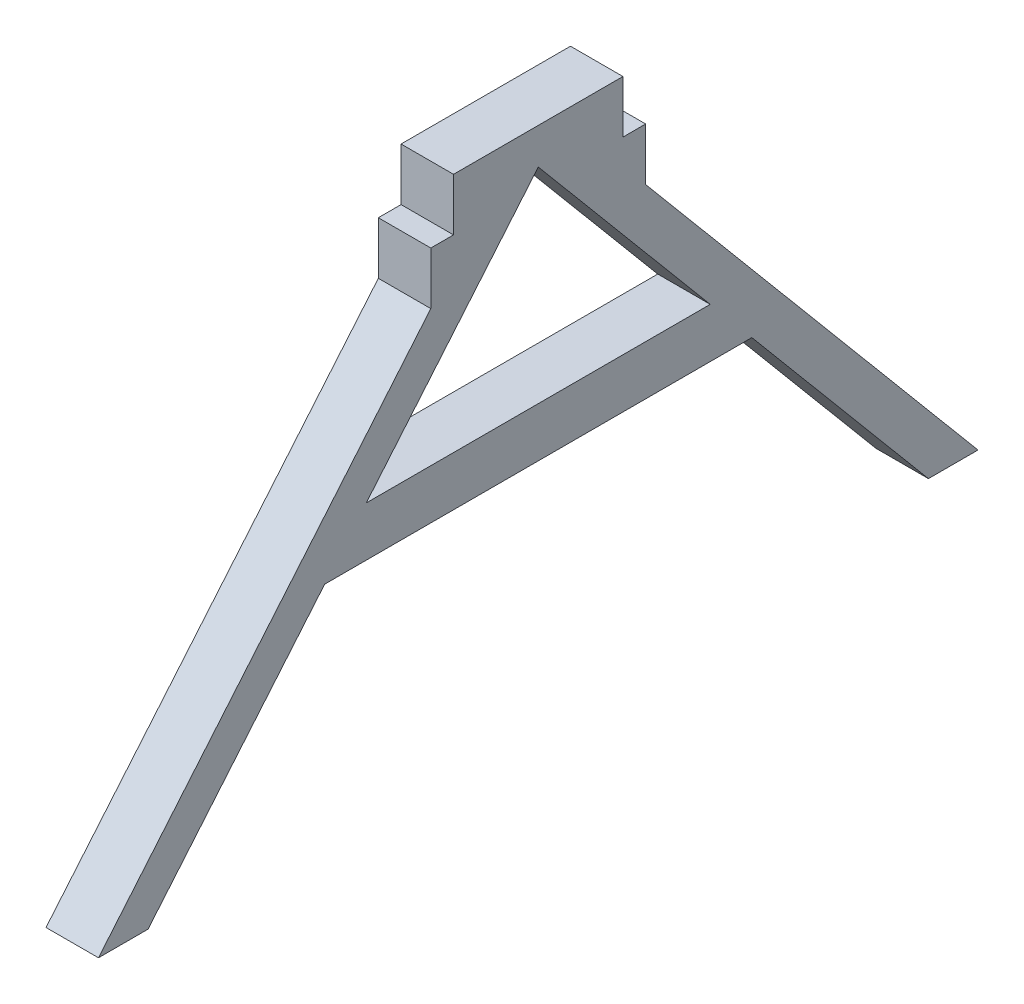
from build123d import *

# Parameters (mm, degrees)
BOSS_EXTRUDE2_DEPTH = 3.175


with BuildPart() as part:
    # Sketch1 → Boss-Extrude2 (new body)
    with BuildSketch(Plane(origin=(0, 0, 0), x_dir=(0, 0, -1), z_dir=(1, 0, 0))):
        Polygon((0.727545577, -5.496236961), (-19.379740188, -29.459167008), (-16.379740188, -29.459167008), (-5.695435338, -16.726108319), (20.150526491, -16.726108319), (30.834831341, -29.459167008), (33.834831341, -29.459167008), (13.727545577, -5.496236961), (13.727545577, -2.321236961), (12.352545577, -2.321236961), (12.352545577, 0.853763039), (2.102545577, 0.853763039), (2.102545577, -2.321236961), (0.727545577, -2.321236961), align=None)
        Polygon((7.227545577, -1.325099387), (17.633227598, -13.726108319), (-3.178136444, -13.726108319), align=None, mode=Mode.SUBTRACT)
    extrude(amount=BOSS_EXTRUDE2_DEPTH)


solid = part.part
